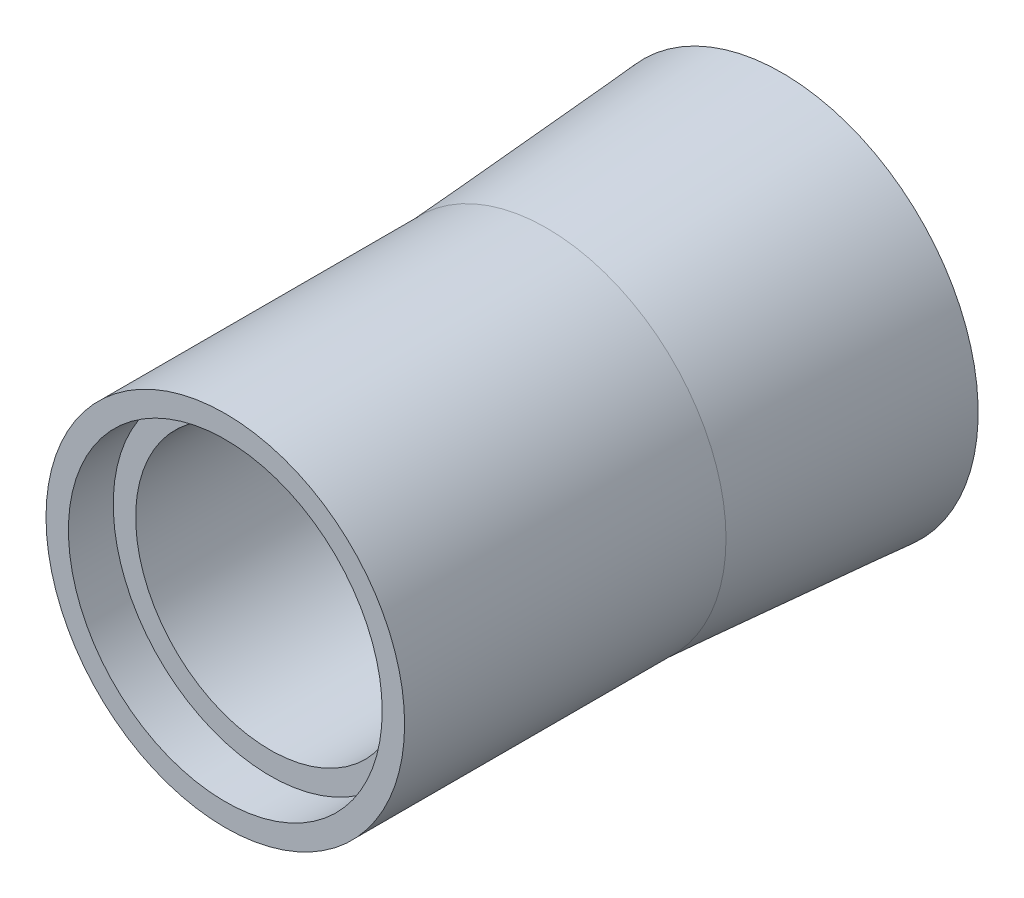
from build123d import *

# Parameters (mm, degrees)
SKETCH1_R           = 50.8
SKETCH1_R_2         = 38.1
BOSS_EXTRUDE1_DEPTH = 157.734
SKETCH2_R           = 38.1
SKETCH2_R_2         = 44.45
CUT_EXTRUDE1_DEPTH  = 12.7


with BuildPart() as part:
    # Sketch1 → Boss-Extrude1 (new body)
    with BuildSketch(Plane.XY):
        Circle(SKETCH1_R)
        Circle(SKETCH1_R_2, mode=Mode.SUBTRACT)
    extrude(amount=BOSS_EXTRUDE1_DEPTH)

    # Sketch2 → Cut-Extrude1 (cut)
    with BuildSketch(Plane.XY.offset(157.734)):
        Circle(SKETCH2_R)
        Circle(SKETCH2_R_2)
        Circle(SKETCH2_R, mode=Mode.SUBTRACT)
    extrude(amount=-CUT_EXTRUDE1_DEPTH, mode=Mode.SUBTRACT)

    # Sketch3 → Revolve1 (revolve)
    with BuildSketch(Plane(origin=(0, 0, 0), x_dir=(1, 0, 0), z_dir=(0, 1, 0))):
        Polygon((55.5625, 0), (50.8, -66.675), (50.8, 0), align=None)
    revolve(axis=Axis((0, 0, 0), (0, 0, 1)))


solid = part.part
